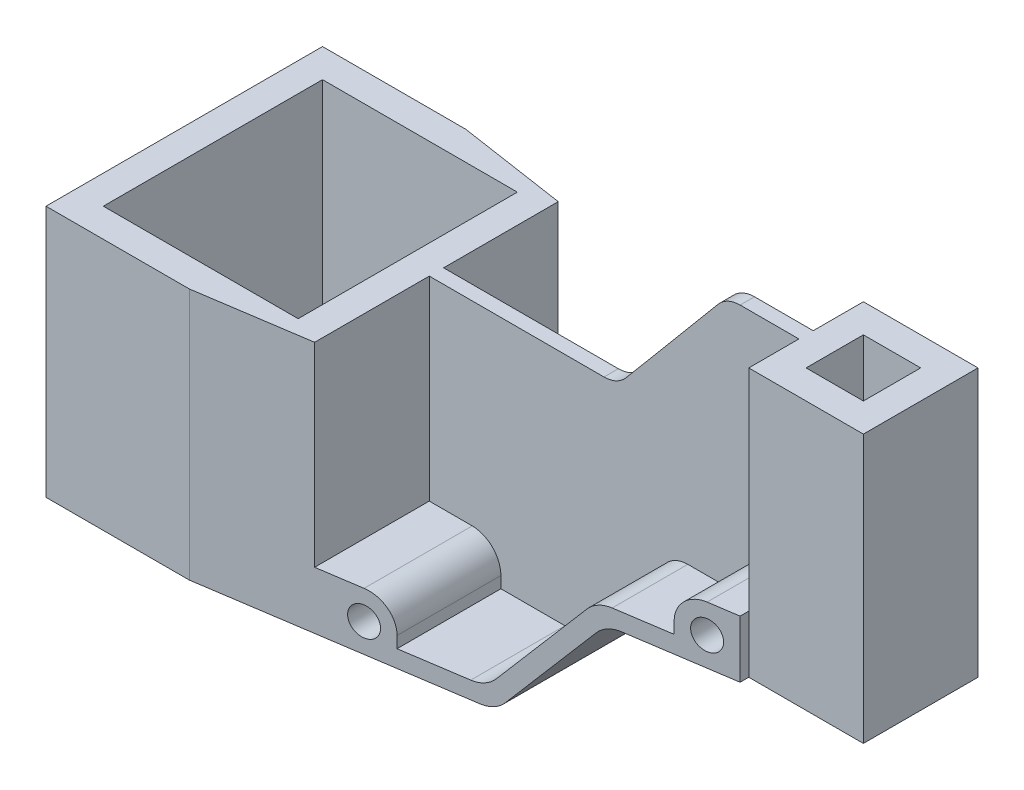
from build123d import *

# Parameters (mm, degrees)
SKETCH1_W           = 257
SKETCH1_H           = 96.5
BOSS_EXTRUDE1_DEPTH = 133.5
SKETCH2_W           = 140
SKETCH2_H           = 96.5
CUT_EXTRUDE1_DEPTH  = 45.5
SKETCH3_W           = 52
SKETCH3_H           = 45.75
CUT_EXTRUDE2_DEPTH  = 68
SKETCH4_W           = 68
SKETCH4_H           = 76.5
CUT_EXTRUDE3_DEPTH  = 89
SKETCH5_R           = 5
CUT_EXTRUDE4_DEPTH  = 45.75
SKETCH6_R           = 5
CUT_EXTRUDE5_DEPTH  = 45.75
SKETCH7_R           = 5
CUT_EXTRUDE6_DEPTH  = 97.5
CUT_EXTRUDE7_DEPTH  = 97.5
CUT_EXTRUDE8_DEPTH  = 97.5
SKETCH10_R          = 5
CUT_EXTRUDE9_DEPTH  = 45.75
CUT_EXTRUDE10_DEPTH = 45.75
SKETCH12_R          = 5
CUT_EXTRUDE11_DEPTH = 97.5
SKETCH13_W          = 40
SKETCH13_H          = 28.25
CUT_EXTRUDE12_DEPTH = 134.5
SKETCH14_W          = 20
SKETCH14_H          = 20
CUT_EXTRUDE13_DEPTH = 134.5
CUT_EXTRUDE14_DEPTH = 89
FILLET1_R           = 10
FILLET2_R           = 10


with BuildPart() as part:
    # Sketch1 → Boss-Extrude1 (new body)
    with BuildSketch(Plane(origin=(0, 0, 0), x_dir=(1, 0, 0), z_dir=(0, 1, 0))):
        with Locations((-128.5, -48.25)):
            Rectangle(SKETCH1_W, SKETCH1_H)
    extrude(amount=BOSS_EXTRUDE1_DEPTH)

    # Sketch2 → Cut-Extrude1 (cut)
    with BuildSketch(Plane(origin=(0, 133.5, 0), x_dir=(1, 0, 0), z_dir=(0, 1, 0))):
        with Locations((-187, -48.25)):
            Rectangle(SKETCH2_W, SKETCH2_H)
    extrude(amount=-CUT_EXTRUDE1_DEPTH, mode=Mode.SUBTRACT)

    # Sketch3 → Cut-Extrude2 (cut)
    with BuildSketch(Plane(origin=(0, 88, 0), x_dir=(1, 0, 0), z_dir=(0, 1, 0))):
        with Locations((-143, -22.875)):
            Rectangle(SKETCH3_W, SKETCH3_H)
        with Locations((-143, -73.625)):
            Rectangle(SKETCH3_W, SKETCH3_H)
    extrude(amount=-CUT_EXTRUDE2_DEPTH, mode=Mode.SUBTRACT)

    # Sketch4 → Cut-Extrude3 (cut, through all)
    with BuildSketch(Plane(origin=(0, 88, 0), x_dir=(1, 0, 0), z_dir=(0, 1, 0))):
        with Locations((-213, -48.25)):
            Rectangle(SKETCH4_W, SKETCH4_H)
    extrude(amount=-CUT_EXTRUDE3_DEPTH, mode=Mode.SUBTRACT)

    # Sketch5 → Cut-Extrude4 (cut)
    with BuildSketch(Plane.XY.offset(96.5)):
        with Locations((-154, 10)):
            Circle(SKETCH5_R)
        with BuildLine():
            Line((-169, 20), (-154, 20))
            ThreePointArc((-154, 20), (-146.928932188, 17.071067812), (-144, 10))
            Line((-144, 10), (-144, 6))
            Line((-144, 6), (-117, 6))
            Line((-117, 6), (-117, 88))
            Line((-117, 88), (-169, 88))
            Line((-169, 88), (-169, 20))
        make_face()
    extrude(amount=-CUT_EXTRUDE4_DEPTH, mode=Mode.SUBTRACT)

    # Sketch6 → Cut-Extrude5 (cut)
    with BuildSketch(Plane(origin=(0, 0, 0), x_dir=(-1, 0, 0), z_dir=(0, 0, -1))):
        with Locations((154, 10)):
            Circle(SKETCH6_R)
        with BuildLine():
            Line((144, 6), (117, 6))
            Line((117, 6), (117, 88))
            Line((117, 88), (169, 88))
            Line((169, 88), (169, 20))
            Line((169, 20), (154, 20))
            ThreePointArc((154, 20), (146.928932188, 17.071067812), (144, 10))
            Line((144, 10), (144, 6))
        make_face()
    extrude(amount=-CUT_EXTRUDE5_DEPTH, mode=Mode.SUBTRACT)

    # Sketch7 → Cut-Extrude6 (cut, through all)
    with BuildSketch(Plane(origin=(0, 0, 0), x_dir=(-1, 0, 0), z_dir=(0, 0, -1))):
        with Locations((154, 10)):
            Circle(SKETCH7_R)
    extrude(amount=-CUT_EXTRUDE6_DEPTH, mode=Mode.SUBTRACT)

    # Sketch8 → Cut-Extrude7 (cut, through all)
    with BuildSketch(Plane.XY.offset(96.5)):
        Polygon((0, 40), (-80.638168804, 40), (-114.202154051, 0), (0, 0), align=None)
    extrude(amount=-CUT_EXTRUDE7_DEPTH, mode=Mode.SUBTRACT)

    # Sketch9 → Cut-Extrude8 (cut, through all)
    with BuildSketch(Plane.XY.offset(96.5)):
        Polygon((-65.168254999, 133.5), (-103.347288218, 88), (-117, 88), (-117, 133.5), align=None)
    extrude(amount=-CUT_EXTRUDE8_DEPTH, mode=Mode.SUBTRACT)

    # Sketch10 → Cut-Extrude9 (cut)
    with BuildSketch(Plane.XY.offset(96.5)):
        with Locations((-50, 50)):
            Circle(SKETCH10_R)
        with BuildLine():
            Line((-83.436014753, 46), (-60, 46))
            Line((-60, 46), (-60, 50))
            ThreePointArc((-60, 50), (-57.071067812, 57.071067812), (-50, 60))
            Line((-50, 60), (-40, 60))
            Line((-40, 60), (-40, 133.5))
            Line((-40, 133.5), (-65.168254999, 133.5))
            Line((-65.168254999, 133.5), (-103.347288218, 88))
            Line((-103.347288218, 88), (-117, 88))
            Line((-117, 88), (-117, 6))
            Line((-117, 6), (-83.436014753, 46))
        make_face()
    extrude(amount=-CUT_EXTRUDE9_DEPTH, mode=Mode.SUBTRACT)

    # Sketch11 → Cut-Extrude10 (cut)
    with BuildSketch(Plane(origin=(0, 0, 0), x_dir=(-1, 0, 0), z_dir=(0, 0, -1))):
        with BuildLine():
            Line((65.168254999, 133.5), (40, 133.5))
            Line((40, 133.5), (40, 60))
            Line((40, 60), (50, 60))
            ThreePointArc((50, 60), (57.071067812, 57.071067812), (60, 50))
            Line((60, 50), (60, 46))
            Line((60, 46), (83.436014753, 46))
            Line((83.436014753, 46), (117, 6))
            Line((117, 6), (117, 88))
            Line((117, 88), (103.347288218, 88))
            Line((103.347288218, 88), (65.168254999, 133.5))
        make_face()
    extrude(amount=-CUT_EXTRUDE10_DEPTH, mode=Mode.SUBTRACT)

    # Sketch12 → Cut-Extrude11 (cut, through all)
    with BuildSketch(Plane(origin=(0, 0, 0), x_dir=(-1, 0, 0), z_dir=(0, 0, -1))):
        with Locations((50, 50)):
            Circle(SKETCH12_R)
    extrude(amount=-CUT_EXTRUDE11_DEPTH, mode=Mode.SUBTRACT)

    # Sketch13 → Cut-Extrude12 (cut, through all)
    with BuildSketch(Plane(origin=(0, 133.5, 0), x_dir=(1, 0, 0), z_dir=(0, 1, 0))):
        with Locations((-20, -82.375)):
            Rectangle(SKETCH13_W, SKETCH13_H)
        with Locations((-20, -14.125)):
            Rectangle(SKETCH13_W, SKETCH13_H)
    extrude(amount=-CUT_EXTRUDE12_DEPTH, mode=Mode.SUBTRACT)

    # Sketch14 → Cut-Extrude13 (cut, through all)
    with BuildSketch(Plane(origin=(0, 133.5, 0), x_dir=(1, 0, 0), z_dir=(0, 1, 0))):
        with Locations((-20, -48.25)):
            Rectangle(SKETCH14_W, SKETCH14_H)
    extrude(amount=-CUT_EXTRUDE13_DEPTH, mode=Mode.SUBTRACT)

    # Sketch15 → Cut-Extrude14 (cut, through all)
    with BuildSketch(Plane(origin=(0, 88, 0), x_dir=(1, 0, 0), z_dir=(0, 1, 0))):
        Polygon((-207, 0), (-20, -28.25), (-20, 0), align=None)
        Polygon((-207, -96.5), (-20, -68.25), (-20, -96.5), align=None)
    extrude(amount=-CUT_EXTRUDE14_DEPTH, mode=Mode.SUBTRACT)

    # Fillet1
    fillet1_edges = [part.edges().sort_by_distance(p)[0] for p in [
        (-117, 6, 29.673128342),
        (-83.436014753, 46, 64.291624109),
        (-65.168254999, 133.5, 48.25),
        (-103.347288218, 88, 48.25),
        (-83.436014753, 46, 32.208375891),
        (-114.202154051, 0, 48.25),
        (-117, 6, 66.826871658),
    ]]
    fillet(fillet1_edges, radius=FILLET1_R)

    # Fillet2
    fillet2_edges = [part.edges().sort_by_distance(p)[0] for p in [
        (-80.638168804, 40, 48.25),
    ]]
    fillet(fillet2_edges, radius=FILLET2_R)


solid = part.part
